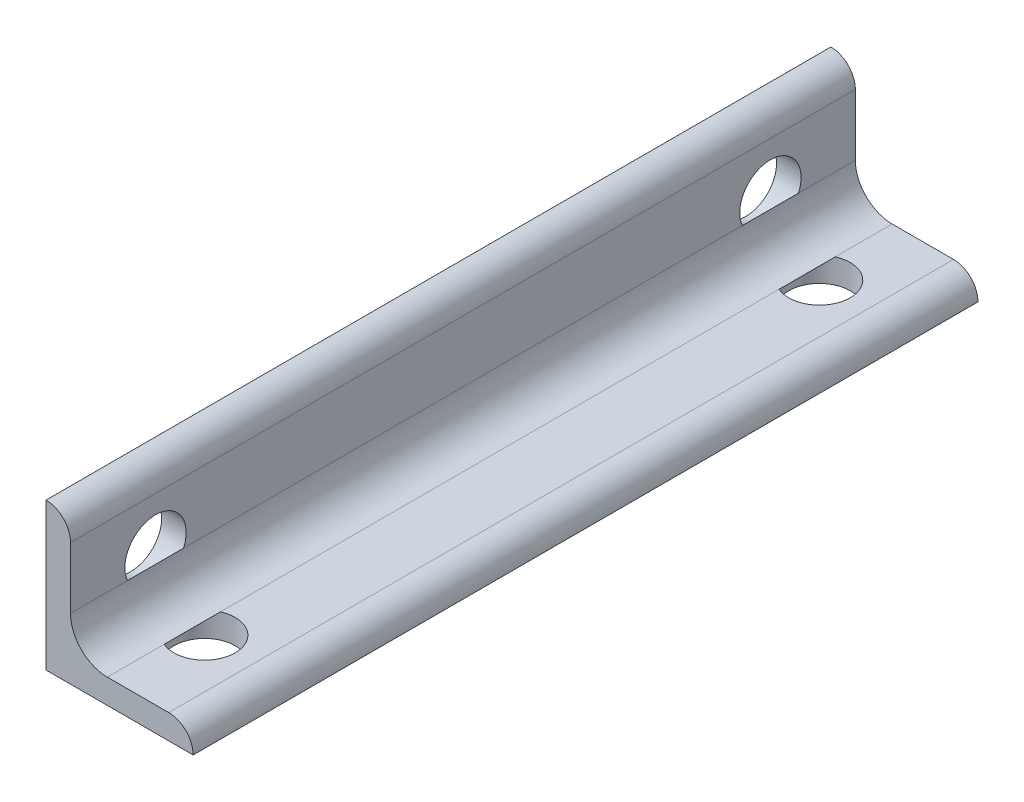
from build123d import *

# Parameters (mm, degrees)
BASESTEELANGLE_DEPTH = 50.8


with BuildPart() as part:
    # Sketch1 → BaseSteelAngle (new body, symmetric)
    with BuildSketch(Plane.XY):
        with BuildLine():
            Line((0, 0), (0, 19.05))
            Line((0, 19.05), (0.00508, 19.05))
            ThreePointArc((0.00508, 19.05), (2.246551928, 18.121551928), (3.175, 15.88008))
            Line((3.175, 15.88008), (3.175, 7.9375))
            ThreePointArc((3.175, 7.9375), (4.569903955, 4.569903955), (7.9375, 3.175))
            Line((7.9375, 3.175), (15.88008, 3.175))
            ThreePointArc((15.88008, 3.175), (18.121551928, 2.246551928), (19.05, 0.00508))
            Line((19.05, 0.00508), (19.05, 0))
            Line((19.05, 0), (0, 0))
        make_face()
    extrude(amount=BASESTEELANGLE_DEPTH, both=True)

    # Sketch4 → 5/16 (0.3125) Diameter Hole2 (revolve, cut)
    with BuildSketch(Plane(origin=(9.525, 3.175, 39.8), x_dir=(0, 0, 1), z_dir=(1, 0, 0))):
        Polygon((0, 0), (0, 21.434665582), (3.96875, 19.05), (3.96875, 0), align=None)
    f_5_16_0_3125_diameter_hole2 = revolve(axis=Axis((9.525, 9.525, 39.8), (0, -1, 0)), mode=Mode.SUBTRACT)

    # Mirror1: 5/16 (0.3125) Diameter Hole2 across plane
    add(f_5_16_0_3125_diameter_hole2.mirror(Plane.XY), mode=Mode.SUBTRACT)

    # Sketch6 → 5/16 (0.3125) Diameter Hole3 (revolve, cut)
    with BuildSketch(Plane(origin=(3.175, 9.525, 39.8), x_dir=(0, 0, -1), z_dir=(0, 1, 0))):
        Polygon((0, 0), (0, 21.434665582), (3.96875, 19.05), (3.96875, 0), align=None)
    f_5_16_0_3125_diameter_hole3 = revolve(axis=Axis((9.525, 9.525, 39.8), (-1, 0, 0)), mode=Mode.SUBTRACT)

    # Mirror2: 5/16 (0.3125) Diameter Hole3 across plane
    add(f_5_16_0_3125_diameter_hole3.mirror(Plane.XY), mode=Mode.SUBTRACT)


solid = part.part
